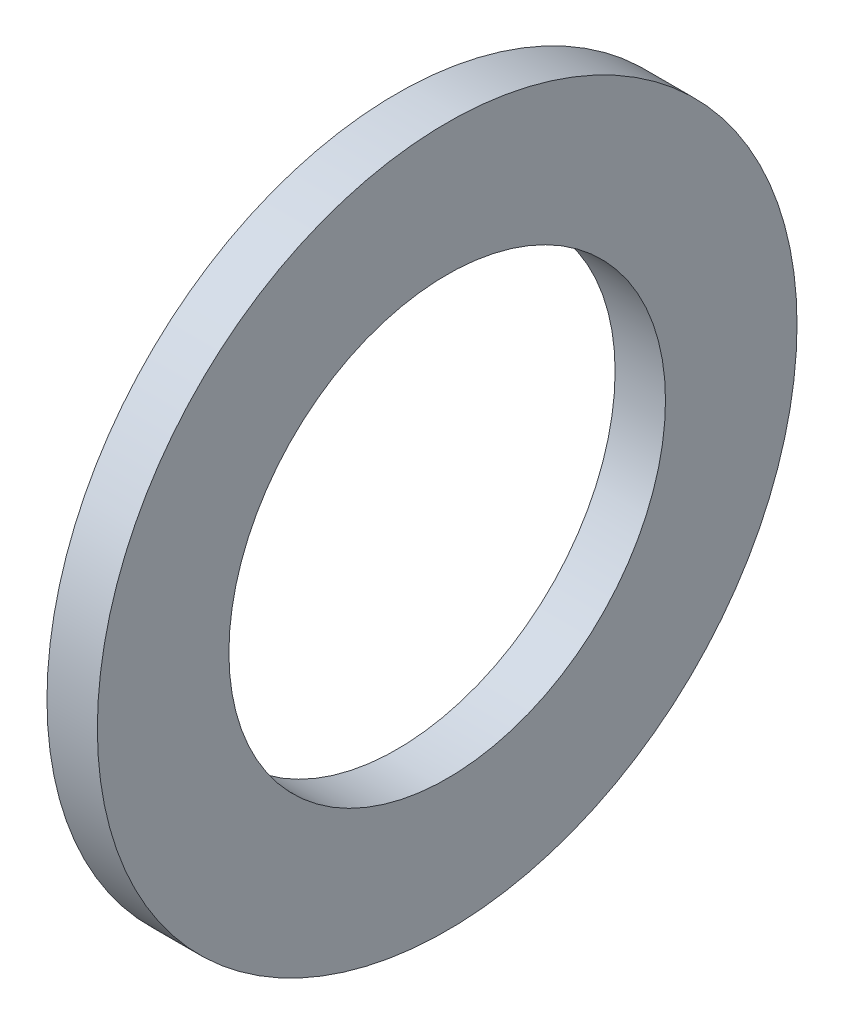
from build123d import *

# Parameters (mm, degrees)
SKETCH1_R           = 6.35
SKETCH1_R_2         = 3.9624
BOSS_EXTRUDE1_DEPTH = 0.9144


with BuildPart() as part:
    # Sketch1 → Boss-Extrude1 (new body)
    with BuildSketch(Plane(origin=(0, 0, 0), x_dir=(0, 0, -1), z_dir=(1, 0, 0))):
        Circle(SKETCH1_R)
        Circle(SKETCH1_R_2, mode=Mode.SUBTRACT)
    extrude(amount=BOSS_EXTRUDE1_DEPTH)


solid = part.part
